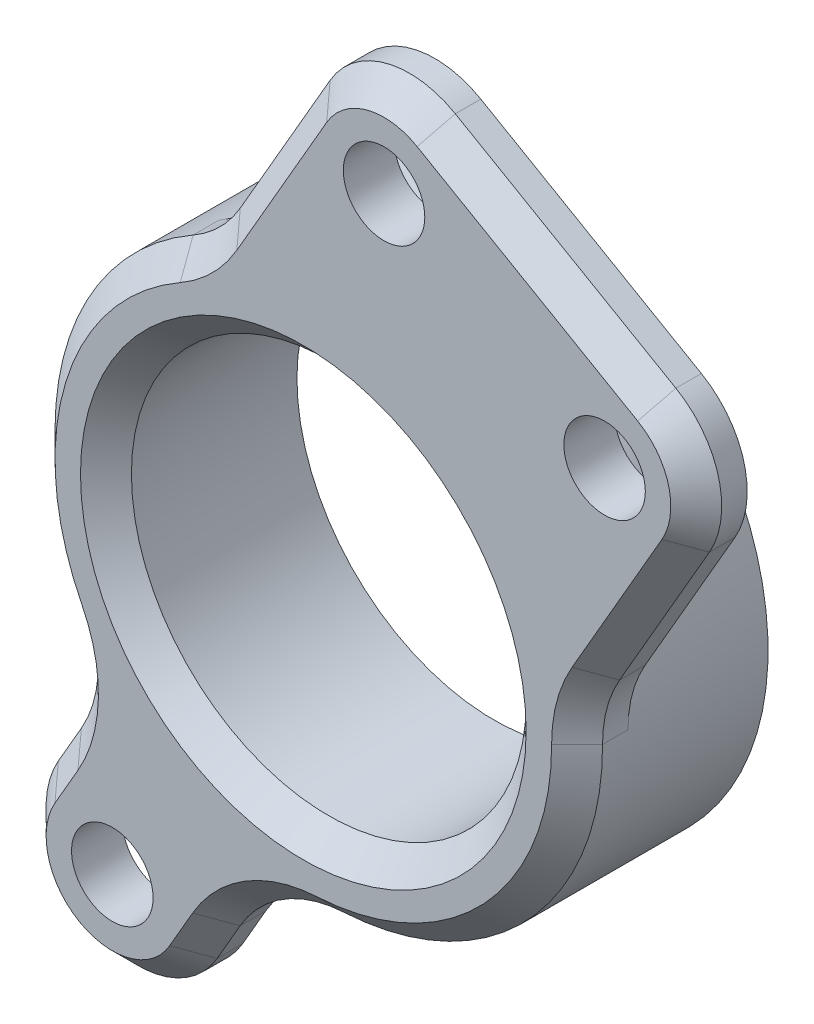
from build123d import *
from build123d.topology import SkipClean

# Parameters (mm, degrees)
SKETCH1_R           = 1.6
SKETCH1_R_2         = 10.75
SKETCH1_R_3         = 7.75
BOSS_EXTRUDE1_DEPTH = 2
SKETCH1_3_R         = 10.75
SKETCH1_3_R_2       = 7.75
BOSS_EXTRUDE2_DEPTH = 5.5
FILLET1_R           = 5
CHAMFER1_SIZE       = 1


with BuildPart() as part:
    # Sketch1 → Boss-Extrude1 (new body)
    with BuildSketch(Plane.XY):
        with BuildLine():
            ThreePointArc((-1.946953154, -10.572221782), (-5.375, -9.309773091), (-8.182336061, -6.972221782))
            Line((-8.182336061, -6.972221782), (-10.617691454, -11.190381057))
            ThreePointArc((-10.617691454, -11.190381057), (-9.3, -16.10807251), (-4.382308546, -14.790381057))
            Line((-4.382308546, -14.790381057), (-1.946953154, -10.572221782))
        make_face()
        with Locations((-7.5, -12.990381057)):
            Circle(SKETCH1_R, mode=Mode.SUBTRACT)
        with BuildLine():
            Line((13.630127019, 13.60807251), (4.969872981, 18.60807251))
            ThreePointArc((4.969872981, 18.60807251), (2.238124419, 18.967714031), (0.052181527, 17.290381057))
            Line((0.052181527, 17.290381057), (-4.222818473, 9.885863854))
            ThreePointArc((-4.222818473, 9.885863854), (5.375, 9.309773091), (10.672818473, 1.285863854))
            Line((10.672818473, 1.285863854), (14.947818473, 8.690381057))
            ThreePointArc((14.947818473, 8.690381057), (15.307459994, 11.422129619), (13.630127019, 13.60807251))
        make_face()
        with Locations((3.169872981, 15.490381057)):
            Circle(SKETCH1_R, mode=Mode.SUBTRACT)
        with Locations((11.830127019, 10.490381057)):
            Circle(SKETCH1_R, mode=Mode.SUBTRACT)
        Circle(SKETCH1_R_2)
        Circle(SKETCH1_R_3, mode=Mode.SUBTRACT)
    extrude(amount=BOSS_EXTRUDE1_DEPTH)

    # Sketch1_3 → Boss-Extrude2 (add)
    with SkipClean():  # the faces are left unmerged after this step: merging them gives an invalid solid
        with BuildSketch(Plane.XY):
            with Locations(Location((0, 0, 0), (0, 0, 180))):
                Circle(SKETCH1_3_R)
            with Locations(Location((0, 0, 0), (0, 0, 180))):
                Circle(SKETCH1_3_R_2, mode=Mode.SUBTRACT)
        extrude(amount=-BOSS_EXTRUDE2_DEPTH)

    # Fillet1
    fillet1_edges = [part.edges().sort_by_distance(p)[0] for p in [
        (-8.182336061, -6.972221782, 1),
        (-4.222818473, 9.885863854, 1),
        (10.672818473, 1.285863854, 1),
        (-1.946953154, -10.572221782, 1),
    ]]
    fillet(fillet1_edges, radius=FILLET1_R)

    # Chamfer1
    chamfer1_edges = [part.edges().sort_by_distance(p)[0] for p in [
        (-10.166389113, -10.408702474, 2),
        (-9.3, -16.10807251, 2),
        (-3.931006206, -14.008702474, 2),
        (13.183745523, 5.63491708, 2),
        (15.307459994, 11.422129619, 2),
        (9.3, 16.10807251, 2),
        (2.238124419, 18.967714031, 2),
        (-1.711891422, 14.23491708, 2),
        (7.822542831, -7.373623509, 2),
        (-10.297016692, 3.08770906, 2),
        (-7.75, 0, 2),
        (-4.27948651, 10.135012665, 2),
        (-9.047037625, -7.26206095, 2),
        (-1.765610454, -11.465994887, 2),
        (10.916921691, 1.3613623, 2),
    ]]
    chamfer(chamfer1_edges, length=CHAMFER1_SIZE)


solid = part.part
